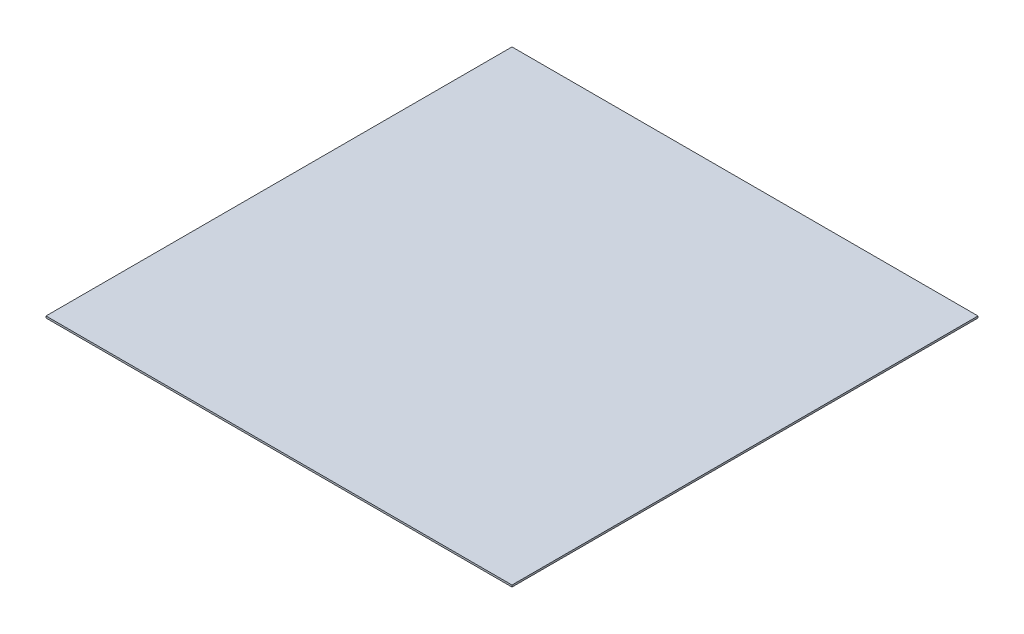
from build123d import *

# Parameters (mm, degrees)
SKETCH1_W           = 510
SKETCH1_H           = 510
BOSS_EXTRUDE1_DEPTH = 2


with BuildPart() as part:
    # Sketch1 → Boss-Extrude1 (new body)
    with BuildSketch(Plane(origin=(0, 0, 0), x_dir=(1, 0, 0), z_dir=(0, 1, 0))):
        Rectangle(SKETCH1_W, SKETCH1_H)
    extrude(amount=BOSS_EXTRUDE1_DEPTH)


solid = part.part
